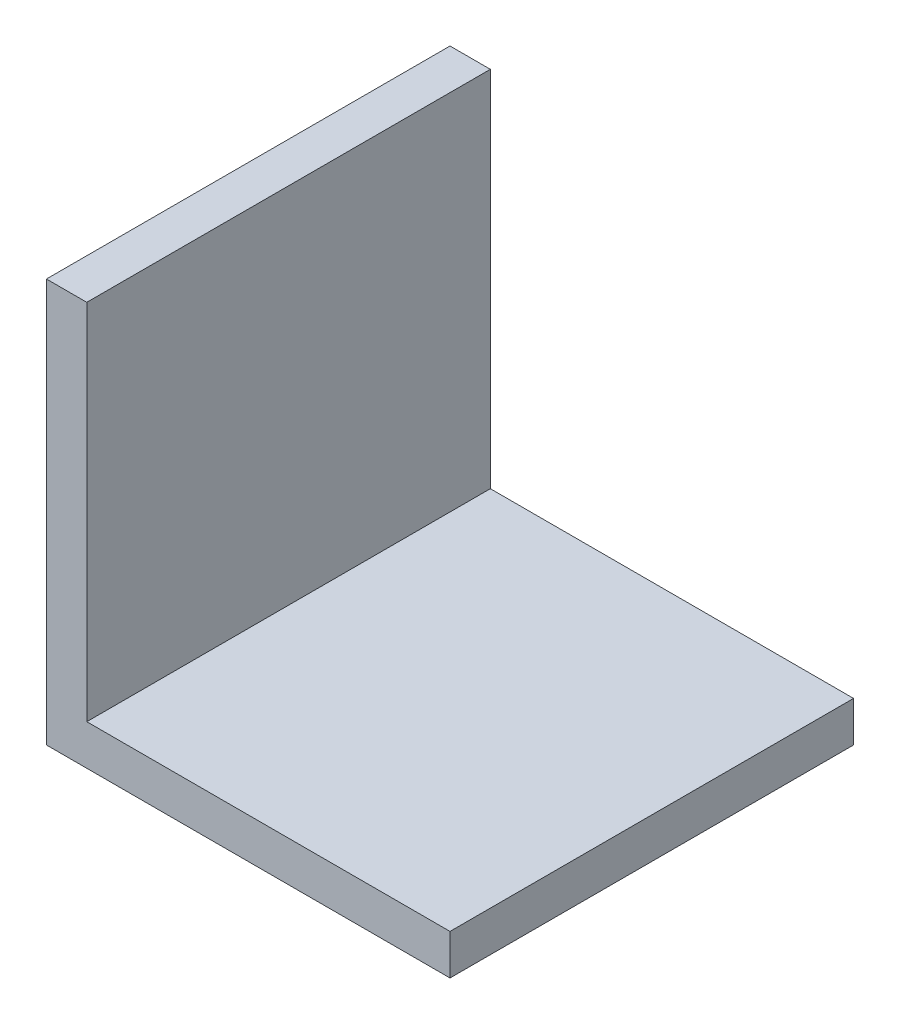
from build123d import *

# Parameters (mm, degrees)
SKETCH1_W           = 30
SKETCH1_H           = 30
BOSS_EXTRUDE1_DEPTH = 30
SHELL1_T            = -3


with BuildPart() as part:
    # Sketch1 → Boss-Extrude1 (new body)
    with BuildSketch(Plane(origin=(0, 0, 0), x_dir=(1, 0, 0), z_dir=(0, 1, 0))):
        with Locations((-60.026365989, -5.886774035)):
            Rectangle(SKETCH1_W, SKETCH1_H)
    extrude(amount=BOSS_EXTRUDE1_DEPTH)

    # Shell1
    shell1_openings = [part.faces().sort_by_distance(p)[0] for p in [
        (-60.026365989, 30, 5.886774035),
        (-60.026365989, 15, -9.113225965),
        (-45.026365989, 15, 5.886774035),
        (-60.026365989, 15, 20.886774035),
    ]]
    offset(amount=SHELL1_T, openings=shell1_openings, kind=Kind.INTERSECTION)


solid = part.part
